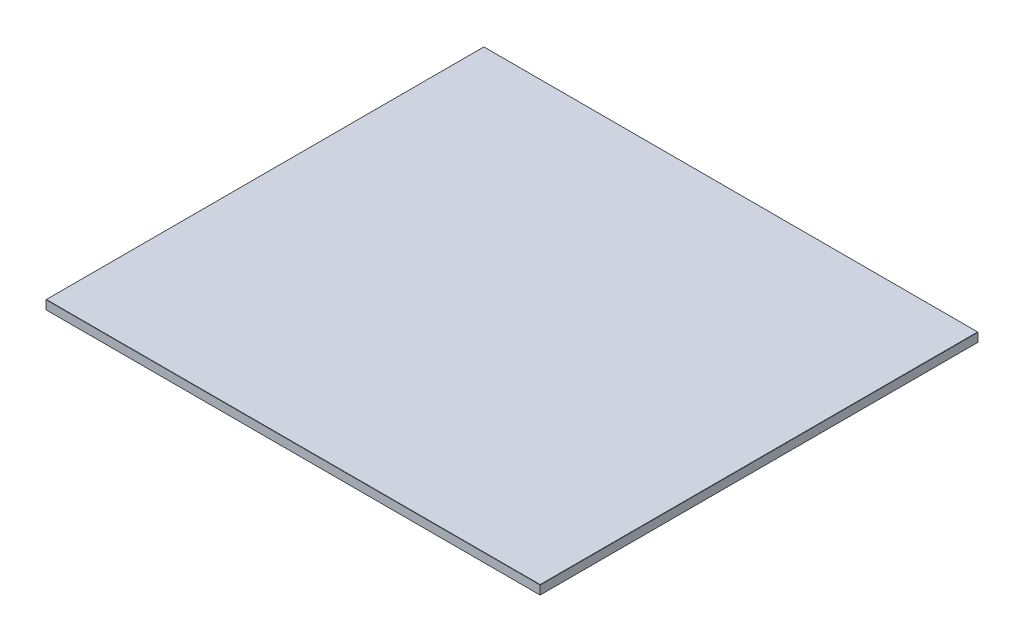
from build123d import *

# Parameters (mm, degrees)
SKETCH1_W           = 650
SKETCH1_H           = 576
BOSS_EXTRUDE1_DEPTH = 12
CHAMFER1_SIZE       = 0.25


with BuildPart() as part:
    # Sketch1 → Boss-Extrude1 (new body)
    with BuildSketch(Plane(origin=(0, 0, 0), x_dir=(1, 0, 0), z_dir=(0, 1, 0))):
        Rectangle(SKETCH1_W, SKETCH1_H)
    extrude(amount=BOSS_EXTRUDE1_DEPTH)

    # Chamfer1
    chamfer1_edges = [part.edges().sort_by_distance(p)[0] for p in [
        (-325, 12, 0),
        (0, 12, 288),
        (325, 12, 0),
        (0, 0, 288),
        (-325, 0, 0),
        (0, 0, -288),
        (325, 0, 0),
        (0, 12, -288),
    ]]
    chamfer(chamfer1_edges, length=CHAMFER1_SIZE)


solid = part.part
